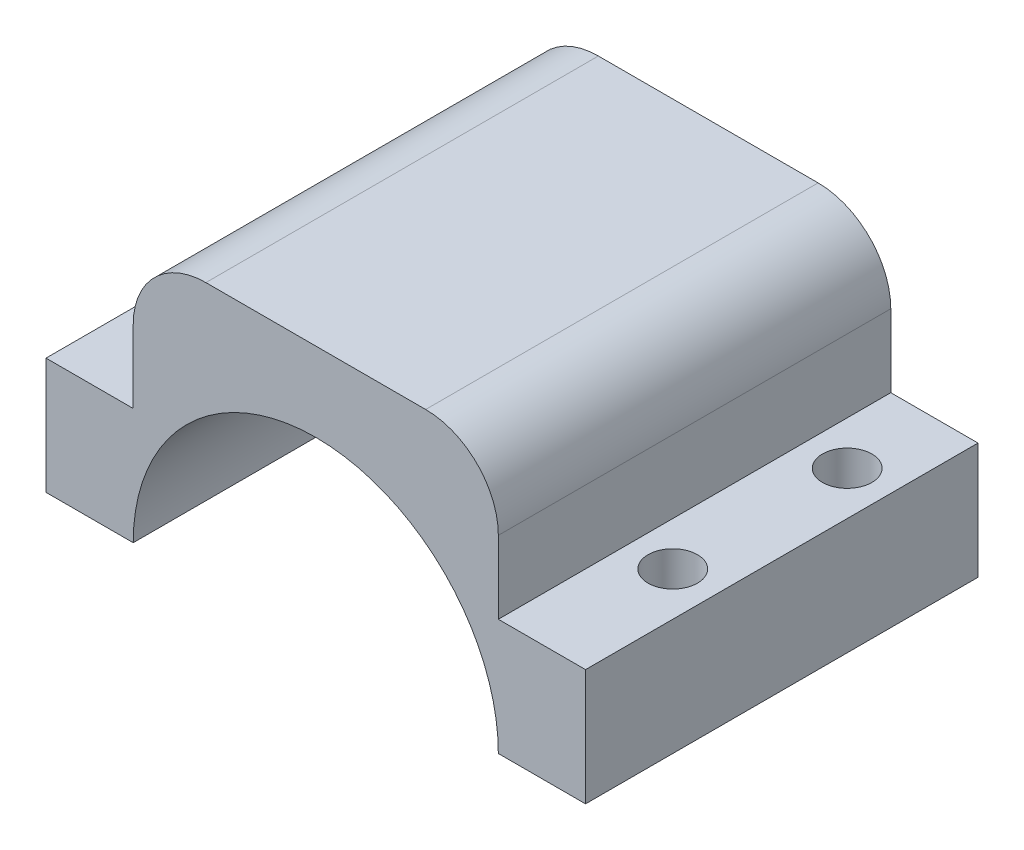
from build123d import *

# Parameters (mm, degrees)
BOSS_EXTRU_1_DEPTH      = 27
ESQUISSE5_R             = 1.7
ENL_V_MAT_EXTRU_1_DEPTH = 18
ESQUISSE6_W             = 6
ESQUISSE6_H             = 27
ENL_V_MAT_EXTRU_2_DEPTH = 10
CONG_1_R                = 5


with BuildPart() as part:
    # Esquisse1 → Boss.-Extru.1 (new body)
    with BuildSketch(Plane.XY):
        with BuildLine():
            Line((-12.560062385, 0), (-18.560062385, 0))
            Line((-18.560062385, 0), (-18.560062385, 18))
            Line((-18.560062385, 18), (18.560062385, 18))
            Line((18.560062385, 18), (18.560062385, 0))
            Line((18.560062385, 0), (12.560062385, 0))
            ThreePointArc((12.560062385, 0), (0, 12.560062385), (-12.560062385, 0))
        make_face()
    extrude(amount=BOSS_EXTRU_1_DEPTH)

    # Esquisse5 → Enlèv. mat.-Extru.1 (cut)
    with BuildSketch(Plane(origin=(0, 18, 0), x_dir=(1, 0, 0), z_dir=(0, 1, 0))):
        with Locations((15.560062385, -6)):
            Circle(ESQUISSE5_R)
        with Locations((15.560062385, -18)):
            Circle(ESQUISSE5_R)
        with Locations((-15.560062385, -6)):
            Circle(ESQUISSE5_R)
        with Locations((-15.560062385, -18)):
            Circle(ESQUISSE5_R)
    extrude(amount=-ENL_V_MAT_EXTRU_1_DEPTH, mode=Mode.SUBTRACT)

    # Esquisse6 → Enlèv. mat.-Extru.2 (cut)
    with BuildSketch(Plane(origin=(0, 18, 0), x_dir=(1, 0, 0), z_dir=(0, 1, 0))):
        with Locations((15.560062385, -13.5)):
            Rectangle(ESQUISSE6_W, ESQUISSE6_H)
        with Locations((-15.560062385, -13.5)):
            Rectangle(ESQUISSE6_W, ESQUISSE6_H)
    extrude(amount=-ENL_V_MAT_EXTRU_2_DEPTH, mode=Mode.SUBTRACT)

    # Congé1
    cong_1_edges = [part.edges().sort_by_distance(p)[0] for p in [
        (12.560062385, 18, 13.5),
        (-12.560062385, 18, 13.5),
    ]]
    fillet(cong_1_edges, radius=CONG_1_R)


solid = part.part
